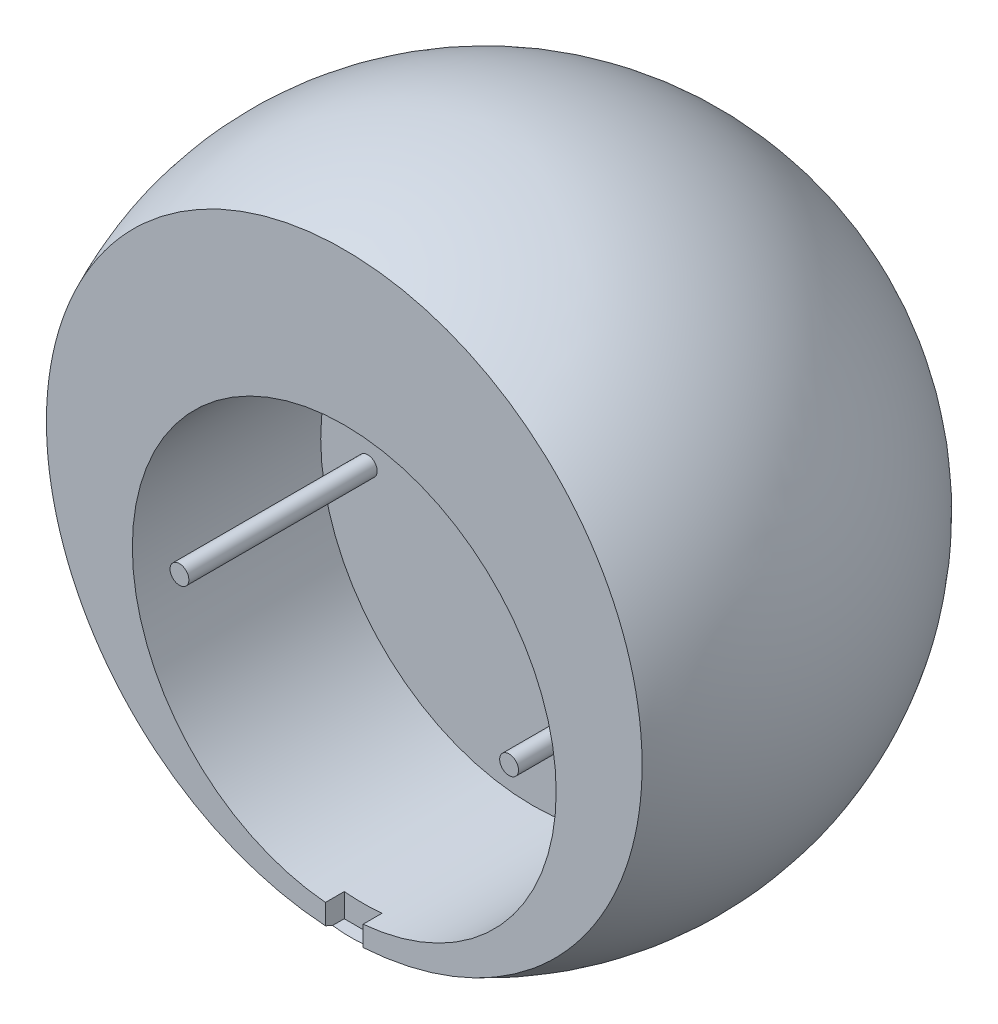
from build123d import *

# Parameters (mm, degrees)
SKETCH6_R           = 22.5
SKETCH6_R_2         = 1
CUT_EXTRUDE8_DEPTH  = 20
SKETCH7_R           = 7.9
CUT_EXTRUDE9_DEPTH  = 20
SKETCH8_W           = 74.606087337
SKETCH8_H           = 72.878153434
CUT_EXTRUDE10_DEPTH = 20
SKETCH10_W          = 4
SKETCH10_H          = 2.5
CUT_EXTRUDE11_DEPTH = 2


with BuildPart() as part:
    # Sketch2 → Revolve1 (revolve)
    with BuildSketch(Plane.XY):
        with BuildLine():
            Line((0, 0), (70, 0))
            ThreePointArc((70, 0), (35, 35), (0, 0))
        make_face()
    revolve(axis=Axis((0, 0, 0), (1, 0, 0)))

    # Sketch6 → Cut-Extrude8 (cut)
    with BuildSketch(Plane.XY.offset(-5)):
        with Locations((35, -7)):
            Circle(SKETCH6_R)
        with Locations((17.5, -7)):
            Circle(SKETCH6_R_2, mode=Mode.SUBTRACT)
        with Locations((52.5, -7)):
            Circle(SKETCH6_R_2, mode=Mode.SUBTRACT)
    extrude(amount=CUT_EXTRUDE8_DEPTH, mode=Mode.SUBTRACT)

    # Sketch7 → Cut-Extrude9 (cut)
    with BuildSketch(Plane.XY.offset(35)):
        with Locations((35, 0)):
            Circle(SKETCH7_R)
    extrude(amount=-CUT_EXTRUDE9_DEPTH, mode=Mode.SUBTRACT)

    # Sketch8 → Cut-Extrude10 (cut)
    with BuildSketch(Plane.XY.offset(35)):
        with Locations((35.203286341, -0.152464756)):
            Rectangle(SKETCH8_W, SKETCH8_H)
    extrude(amount=-CUT_EXTRUDE10_DEPTH, mode=Mode.SUBTRACT)

    # Sketch10 → Cut-Extrude11 (cut)
    with BuildSketch(Plane.XY.offset(15)):
        with Locations((35, -30.660934831)):
            Rectangle(SKETCH10_W, SKETCH10_H)
    extrude(amount=-CUT_EXTRUDE11_DEPTH, mode=Mode.SUBTRACT)


solid = part.part
